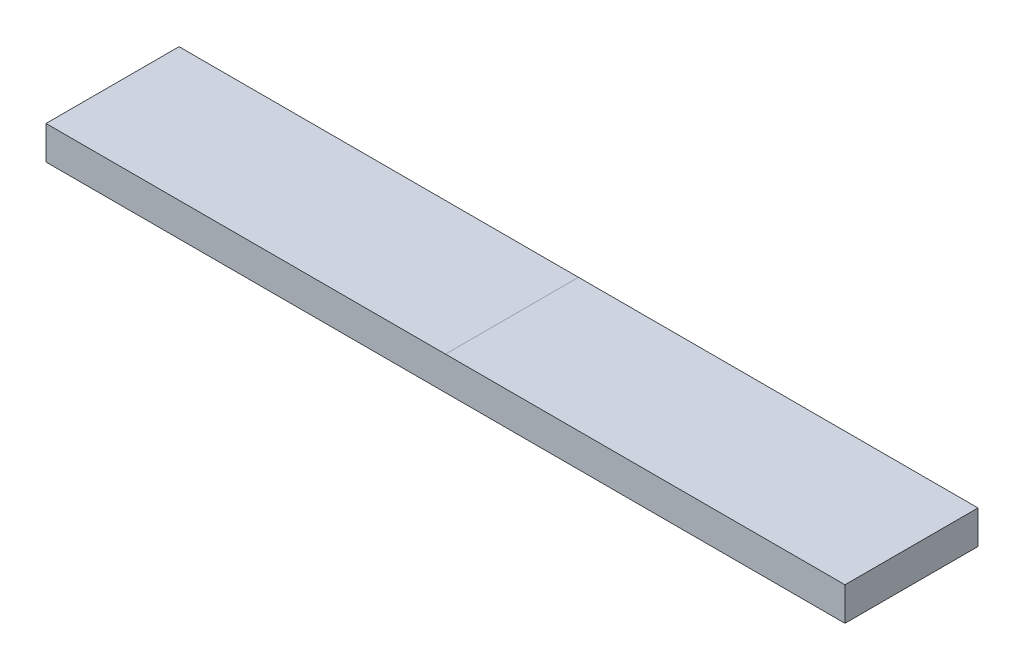
from build123d import *

# Parameters (mm, degrees)
SKETCH1_W           = 25.3746
SKETCH1_H           = 6.3754
BOSS_EXTRUDE1_DEPTH = 76.2


with BuildPart() as part:
    # Sketch1 → Boss-Extrude1 (new body, symmetric)
    with BuildSketch(Plane(origin=(0, 0, 0), x_dir=(0, 0, -1), z_dir=(1, 0, 0))):
        Rectangle(SKETCH1_W, SKETCH1_H)
    extrude(amount=BOSS_EXTRUDE1_DEPTH, both=True)


solid = part.part
